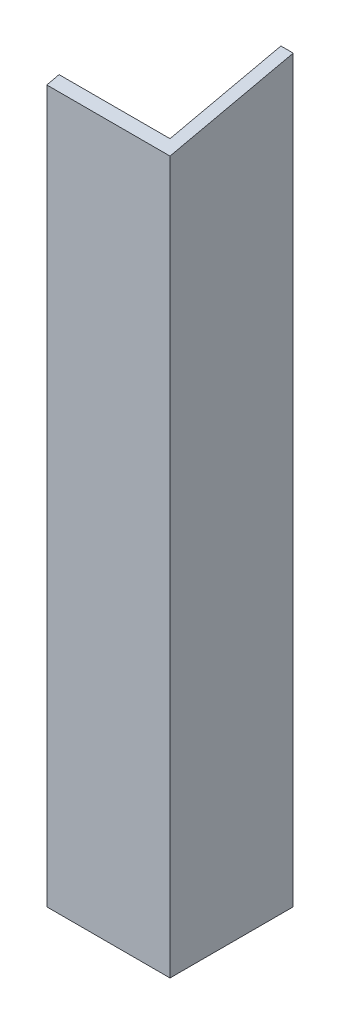
from build123d import *

# Parameters (mm, degrees)
SKETCH1_W           = 20
SKETCH1_H           = 120
BOSS_EXTRUDE1_DEPTH = 20
CUT_EXTRUDE2_DEPTH  = 20
SKETCH5_W           = 18
SKETCH5_H           = 18
CUT_EXTRUDE4_DEPTH  = 120


with BuildPart() as part:
    # Sketch1 → Boss-Extrude1 (new body)
    with BuildSketch(Plane.XY):
        with Locations((6.772727273, -55.795454545)):
            Rectangle(SKETCH1_W, SKETCH1_H)
    extrude(amount=-BOSS_EXTRUDE1_DEPTH)

    # Sketch4 → Cut-Extrude2 (cut)
    with BuildSketch(Plane.ZY.offset(3.227272727)):
        Polygon((-20, 4.204545455), (0, -0.265984203), (0, 4.204545455), align=None)
    extrude(amount=-CUT_EXTRUDE2_DEPTH, mode=Mode.SUBTRACT)

    # Sketch5 → Cut-Extrude4 (cut)
    with BuildSketch(Plane.XZ.offset(115.795454545)):
        with Locations((5.772727273, -11)):
            Rectangle(SKETCH5_W, SKETCH5_H)
    extrude(amount=-CUT_EXTRUDE4_DEPTH, mode=Mode.SUBTRACT)


solid = part.part
